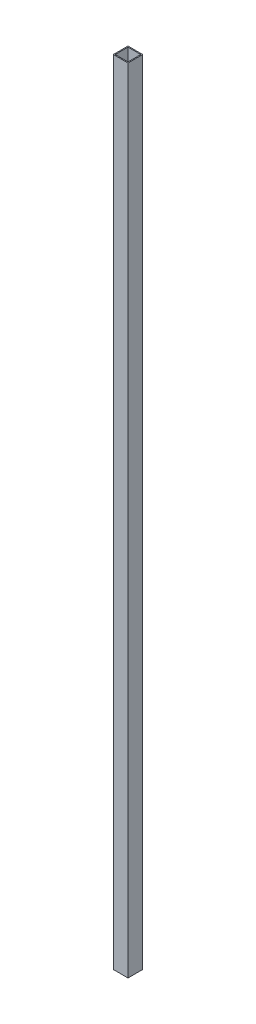
from build123d import *

# Parameters (mm, degrees)
SKETCH2_W           = 30
SKETCH2_H           = 30
SKETCH2_W_2         = 26
SKETCH2_H_2         = 26
BOSS_EXTRUDE1_DEPTH = 807.5


with BuildPart() as part:
    # Sketch2 → Boss-Extrude1 (new body, symmetric)
    with BuildSketch(Plane(origin=(0, 0, 0), x_dir=(1, 0, 0), z_dir=(0, 1, 0))):
        Rectangle(SKETCH2_W, SKETCH2_H)
        Rectangle(SKETCH2_W_2, SKETCH2_H_2, mode=Mode.SUBTRACT)
    extrude(amount=BOSS_EXTRUDE1_DEPTH, both=True)


solid = part.part
